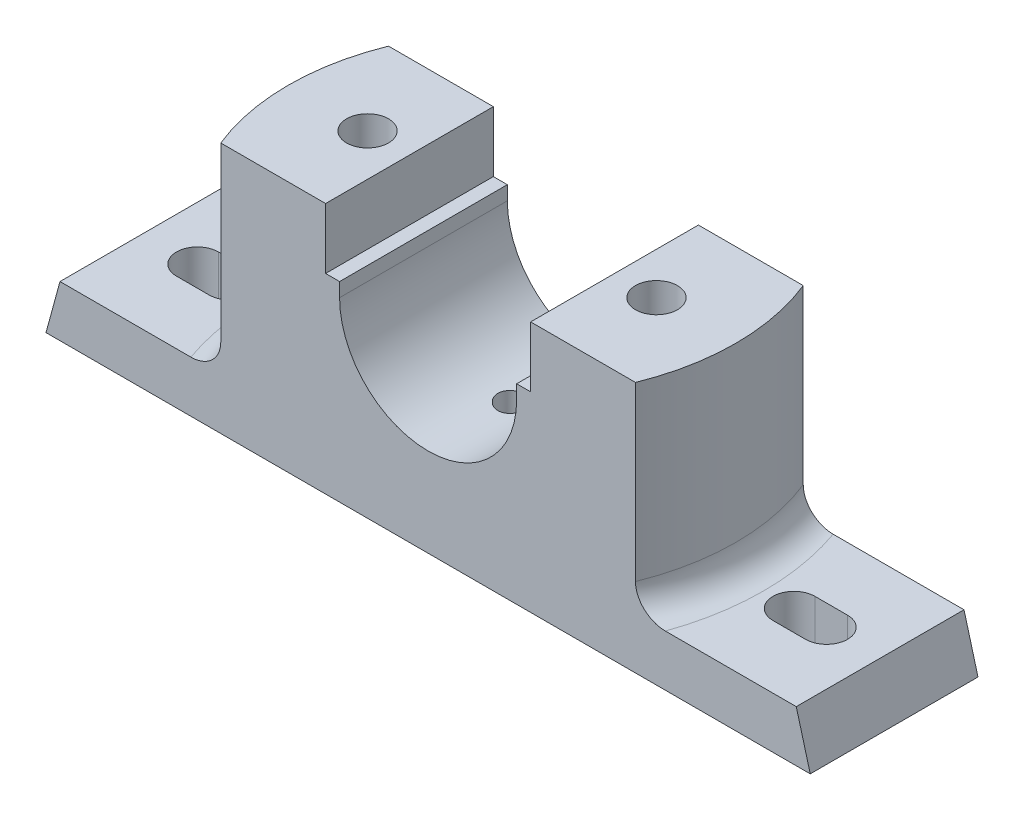
from build123d import *

# Parameters (mm, degrees)
BOSS_EXTRUDE3_DEPTH       = 18
CUT_EXTRUDE1_DEPTH        = 43
F_8_0MM_DOWEL_HOLE1_D     = 6
F_8_0MM_DOWEL_HOLE1_DEPTH = 6
F_8_0MM_DOWEL_HOLE1_TIP   = 1.802581857
M10_TAPPED_HOLE1_D        = 9
SKETCH9_W                 = 20
SKETCH9_H                 = 20
CUT_EXTRUDE2_DEPTH        = 8
CUT_EXTRUDE3_DEPTH        = 11
FILLET2_R                 = 6
FILLET3_R                 = 6


with BuildPart() as part:
    # Sketch1 → Boss-Extrude3 (new body, symmetric)
    with BuildSketch(Plane.XY):
        with BuildLine():
            Line((-82, -43.82348407), (82, -43.82348407))
            Line((82, -43.82348407), (79, -32.82348407))
            Line((79, -32.82348407), (50, -32.82348407))
            Line((50, -32.82348407), (50, 10.17651593))
            Line((50, 10.17651593), (22, 10.17651593))
            Line((22, 10.17651593), (22, -2.82348407))
            Line((22, -2.82348407), (19, -2.82348407))
            Line((19, -2.82348407), (19, -5.82348407))
            ThreePointArc((19, -5.82348407), (0, -24.82348407), (-19, -5.82348407))
            Line((-19, -5.82348407), (-19, -2.82348407))
            Line((-19, -2.82348407), (-22, -2.82348407))
            Line((-22, -2.82348407), (-22, 10.17651593))
            Line((-22, 10.17651593), (-50, 10.17651593))
            Line((-50, 10.17651593), (-50, -32.82348407))
            Line((-50, -32.82348407), (-79, -32.82348407))
            Line((-79, -32.82348407), (-82, -43.82348407))
        make_face()
    extrude(amount=BOSS_EXTRUDE3_DEPTH, both=True)

    # Sketch3 → Cut-Extrude1 (cut)
    with BuildSketch(Plane(origin=(0, 10.17651593, 0), x_dir=(1, 0, 0), z_dir=(0, 1, 0))):
        with BuildLine():
            Line((-44.497190923, 18), (-50, 18))
            Line((-50, 18), (-50, -18))
            Line((-50, -18), (-44.497190923, -18))
            ThreePointArc((-44.497190923, -18), (-48, 0), (-44.497190923, 18))
        make_face()
    cut_extrude1 = extrude(amount=-CUT_EXTRUDE1_DEPTH, mode=Mode.SUBTRACT)

    # Mirror1: Cut-Extrude1 across plane
    add(cut_extrude1.mirror(Plane(origin=(0, 0, 0), x_dir=(0, 0, 1), z_dir=(1, 0, 0))), mode=Mode.SUBTRACT)

    # Ø8.0mm Dowel Hole1
    with Locations(Plane(origin=(0, -24.82348407, 0), x_dir=(1, 0, 0), z_dir=(0, 1, 0))):
        with Locations((0, 0)):
            Hole(F_8_0MM_DOWEL_HOLE1_D / 2, depth=F_8_0MM_DOWEL_HOLE1_DEPTH)
            with Locations((0, 0, -(F_8_0MM_DOWEL_HOLE1_DEPTH + F_8_0MM_DOWEL_HOLE1_TIP / 2))):  # 118° drill point
                Cone(0, F_8_0MM_DOWEL_HOLE1_D / 2, F_8_0MM_DOWEL_HOLE1_TIP, mode=Mode.SUBTRACT)

    # M10 Tapped Hole1 (through all)
    with Locations(Plane(origin=(0, 10.17651593, 0), x_dir=(1, 0, 0), z_dir=(0, 1, 0))):
        with Locations((-31, 0)):
            m10_tapped_hole1 = Hole(M10_TAPPED_HOLE1_D / 2)

    # Sketch9 → Cut-Extrude2 (cut)
    with BuildSketch(Plane.XZ.offset(43.82348407)):
        with Locations((-31, 0)):
            Rectangle(SKETCH9_W, SKETCH9_H)
    cut_extrude2 = extrude(amount=-CUT_EXTRUDE2_DEPTH, mode=Mode.SUBTRACT)

    # Sketch10 → Cut-Extrude3 (cut)
    with BuildSketch(Plane.XZ.offset(43.82348407)):
        with BuildLine():
            Line((-67.5, 4.5), (-60.5, 4.5))
            ThreePointArc((-60.5, 4.5), (-56, 0), (-60.5, -4.5))
            Line((-60.5, -4.5), (-67.5, -4.5))
            ThreePointArc((-67.5, -4.5), (-72, 0), (-67.5, 4.5))
        make_face()
    cut_extrude3 = extrude(amount=-CUT_EXTRUDE3_DEPTH, mode=Mode.SUBTRACT)

    # Mirror2: M10 Tapped Hole1, Cut-Extrude2, Cut-Extrude3 across plane
    add(m10_tapped_hole1.mirror(Plane(origin=(0, 0, 0), x_dir=(0, 0, 1), z_dir=(1, 0, 0))), mode=Mode.SUBTRACT)
    add(cut_extrude2.mirror(Plane(origin=(0, 0, 0), x_dir=(0, 0, 1), z_dir=(1, 0, 0))), mode=Mode.SUBTRACT)
    add(cut_extrude3.mirror(Plane(origin=(0, 0, 0), x_dir=(0, 0, 1), z_dir=(1, 0, 0))), mode=Mode.SUBTRACT)

    # Fillet2
    fillet2_edges = [part.edges().sort_by_distance(p)[0] for p in [
        (-48, -32.82348407, 0),
    ]]
    fillet(fillet2_edges, radius=FILLET2_R)

    # Fillet3
    fillet3_edges = [part.edges().sort_by_distance(p)[0] for p in [
        (48, -32.82348407, 0),
    ]]
    fillet(fillet3_edges, radius=FILLET3_R)


solid = part.part
